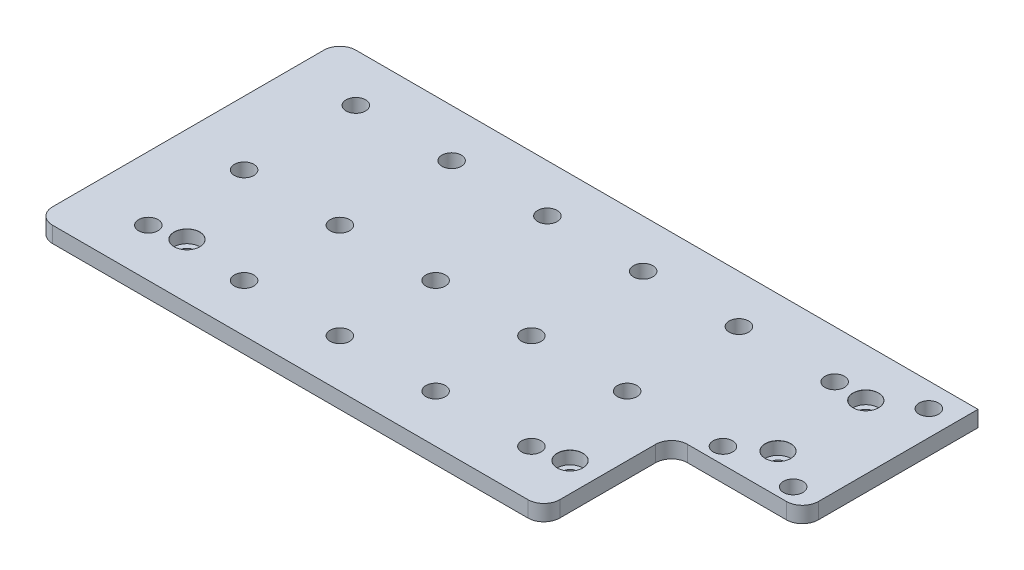
from build123d import *

# Parameters (mm, degrees)
SKETCH1_W                     = 199.9
SKETCH1_H                     = 95
BOSS_EXTRUDE1_DEPTH           = 5
CBORE_FOR_M4_SHCS1_AT_2_COUNT = 2
CBORE_FOR_M4_SHCS1_AT_2_PITCH = 69.462381906
CBORE_FOR_M4_SHCS1_AT_3_COUNT = 2
CBORE_FOR_M4_SHCS1_AT_3_PITCH = 162.557751276
CBORE_FOR_M4_SHCS1_AT_4_COUNT = 2
CBORE_FOR_M4_SHCS1_AT_4_PITCH = 27.5
F_6_1_6_1_DIAMETER_HOLE1_D    = 6.1
LPATTERN1_COUNT               = 2
LPATTERN1_PITCH               = 35
SKETCH6_W                     = 41
SKETCH6_H                     = 40
CUT_EXTRUDE1_DEPTH            = 6
LPATTERN2_COUNT               = 2
LPATTERN2_PITCH               = 65
FILLET1_R                     = 5
F_6_1_6_1_DIAMETER_HOLE2_D    = 6.1
FILLET2_R                     = 5


with BuildPart() as part:
    # Sketch1 → Boss-Extrude1 (new body)
    with BuildSketch(Plane(origin=(0, 0, 0), x_dir=(1, 0, 0), z_dir=(0, 1, 0))):
        with Locations((99.95, -47.5)):
            Rectangle(SKETCH1_W, SKETCH1_H)
    extrude(amount=BOSS_EXTRUDE1_DEPTH)

    # Sketch3 → CBORE for M4 SHCS1 (revolve, cut)
    with BuildSketch(Plane(origin=(179.9, 5, 15.15), x_dir=(0, 0, 1), z_dir=(1, 0, 0))):
        Polygon((0, 0), (0, 5), (2.25, 5), (2.25, 4), (4, 4), (4, 0.025), (4.025, 0), align=None)
    cbore_for_m4_shcs1 = revolve(axis=Axis((179.9, 11.35, 15.15), (0, -1, 0)), mode=Mode.SUBTRACT)

    # CBORE for M4 SHCS1 at 2: CBORE for M4 SHCS1 ×2
    with Locations(*[Vector(-0.431888443, 0, 0.901927033) * (i * CBORE_FOR_M4_SHCS1_AT_2_PITCH) for i in range(1, CBORE_FOR_M4_SHCS1_AT_2_COUNT)]):
        add(cbore_for_m4_shcs1, mode=Mode.SUBTRACT)

    # CBORE for M4 SHCS1 at 3: CBORE for M4 SHCS1 ×2
    with Locations(*[Vector(-0.922748985, 0, 0.385401493) * (i * CBORE_FOR_M4_SHCS1_AT_3_PITCH) for i in range(1, CBORE_FOR_M4_SHCS1_AT_3_COUNT)]):
        add(cbore_for_m4_shcs1, mode=Mode.SUBTRACT)

    # CBORE for M4 SHCS1 at 4: CBORE for M4 SHCS1 ×2
    with Locations(*[(0, 0, i * CBORE_FOR_M4_SHCS1_AT_4_PITCH) for i in range(1, CBORE_FOR_M4_SHCS1_AT_4_COUNT)]):
        add(cbore_for_m4_shcs1, mode=Mode.SUBTRACT)

    # Ø6.1 (6.1) Diameter Hole1 (through all)
    with Locations(Plane(origin=(0, 5, 0), x_dir=(1, 0, 0), z_dir=(0, 1, 0))):
        with Locations((170, -15), (20, -15), (50, -15), (80, -15), (110, -15), (140, -15)):
            f_6_1_6_1_diameter_hole1 = Hole(F_6_1_6_1_DIAMETER_HOLE1_D / 2)

    # LPattern1: Ø6.1 (6.1) Diameter Hole1 ×2
    with Locations(*[(0, 0, i * LPATTERN1_PITCH) for i in range(1, LPATTERN1_COUNT)]):
        add(f_6_1_6_1_diameter_hole1, mode=Mode.SUBTRACT)

    # Sketch6 → Cut-Extrude1 (cut, through all)
    with BuildSketch(Plane(origin=(0, 5, 0), x_dir=(1, 0, 0), z_dir=(0, 1, 0))):
        with Locations((179.4, -75)):
            Rectangle(SKETCH6_W, SKETCH6_H)
    extrude(amount=-CUT_EXTRUDE1_DEPTH, mode=Mode.SUBTRACT)

    # LPattern2: Ø6.1 (6.1) Diameter Hole1 ×2
    with Locations(*[(0, 0, i * LPATTERN2_PITCH) for i in range(1, LPATTERN2_COUNT)]):
        add(f_6_1_6_1_diameter_hole1, mode=Mode.SUBTRACT)

    # Fillet1
    fillet1_edges = [part.edges().sort_by_distance(p)[0] for p in [
        (199.9, 2.5, 55),
        (158.9, 2.5, 95),
        (158.9, 2.5, 55),
    ]]
    fillet(fillet1_edges, radius=FILLET1_R)

    # Ø6.1 (6.1) Diameter Hole2 (through all)
    with Locations(Plane(origin=(0, 5, 0), x_dir=(1, 0, 0), z_dir=(0, 1, 0))):
        with Locations((192, -50), (192, -7.5)):
            Hole(F_6_1_6_1_DIAMETER_HOLE2_D / 2)

    # Fillet2
    fillet2_edges = [part.edges().sort_by_distance(p)[0] for p in [
        (0, 2.5, 0),
        (0, 2.5, 95),
    ]]
    fillet(fillet2_edges, radius=FILLET2_R)


solid = part.part
